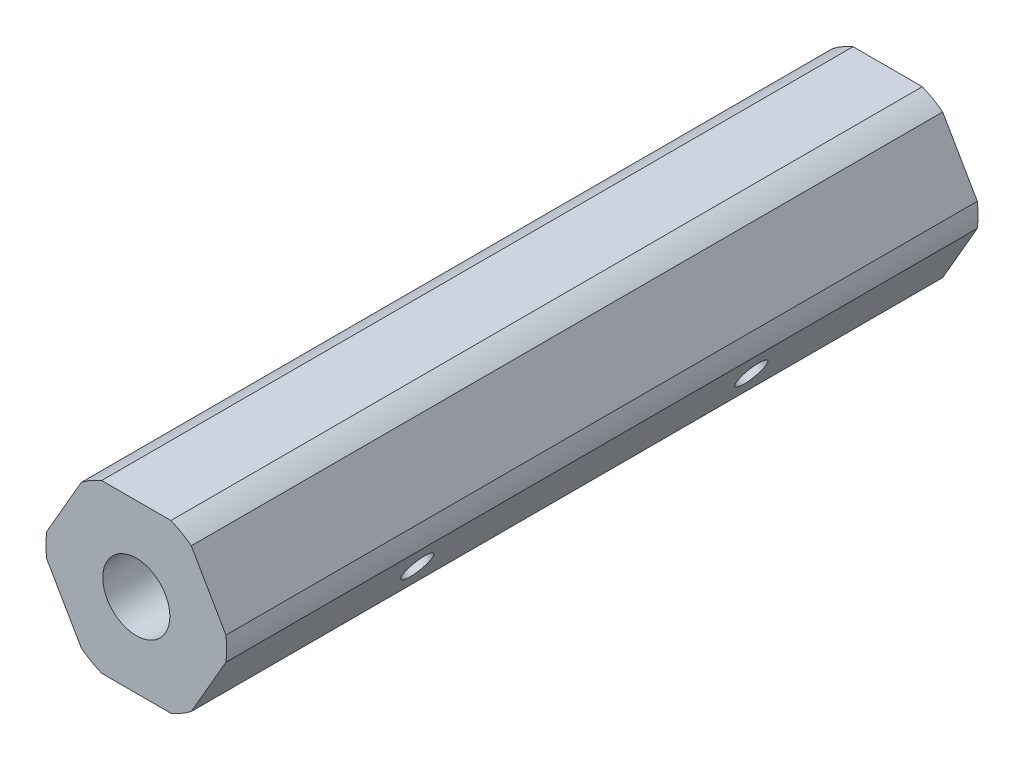
from build123d import *

# Parameters (mm, degrees)
BOSS_EXTRUDE1_DEPTH     = 28.575
F_1_4_20_TAPPED_HOLE1_D = 5.1054
F_4_40_TAPPED_HOLE1_D   = 2.2606
F_4_40_TAPPED_HOLE2_D   = 2.2606


with BuildPart() as part:
    # Sketch1 → Boss-Extrude1 (new body, symmetric)
    with BuildSketch(Plane.XY):
        with BuildLine():
            Line((-2.634981025, -6.35), (2.634981025, -6.35))
            ThreePointArc((2.634981025, -6.35), (3.4375, -5.953924651), (4.181770802, -5.456960506))
            Line((4.181770802, -5.456960506), (6.816751826, -0.893039494))
            ThreePointArc((6.816751826, -0.893039494), (6.875, 0), (6.816751826, 0.893039494))
            Line((6.816751826, 0.893039494), (4.181770802, 5.456960506))
            ThreePointArc((4.181770802, 5.456960506), (3.4375, 5.953924651), (2.634981025, 6.35))
            Line((2.634981025, 6.35), (-2.634981025, 6.35))
            ThreePointArc((-2.634981025, 6.35), (-3.4375, 5.953924651), (-4.181770802, 5.456960506))
            Line((-4.181770802, 5.456960506), (-6.816751826, 0.893039494))
            ThreePointArc((-6.816751826, 0.893039494), (-6.875, 0), (-6.816751826, -0.893039494))
            Line((-6.816751826, -0.893039494), (-4.181770802, -5.456960506))
            ThreePointArc((-4.181770802, -5.456960506), (-3.4375, -5.953924651), (-2.634981025, -6.35))
        make_face()
    extrude(amount=BOSS_EXTRUDE1_DEPTH, both=True)

    # 1/4-20 Tapped Hole1 (through all)
    with Locations(Plane.XY.offset(28.575)):
        with Locations((0, 0)):
            Hole(F_1_4_20_TAPPED_HOLE1_D / 2)

    # #4-40 Tapped Hole1 (through all)
    with Locations(Plane(origin=(0.736761314, -11.423891971, -31.75), x_dir=(0, 0, -1), z_dir=(0.866025404, -0.5, 0))):
        with Locations((-44.45, 120.65), (-19.05, 120.65), (-19.05, 9.525), (-44.45, 9.525)):
            Hole(F_4_40_TAPPED_HOLE1_D / 2)

    # #4-40 Tapped Hole2 (through all)
    with Locations(Plane(origin=(-54.825738686, -107.660964967, -31.75), x_dir=(0, 0, -1), z_dir=(0.866025404, -0.5, 0))):
        with Locations((-44.45, 120.65), (-19.05, 120.65), (-19.05, 9.525), (-44.45, 9.525)):
            Hole(F_4_40_TAPPED_HOLE2_D / 2)


solid = part.part
